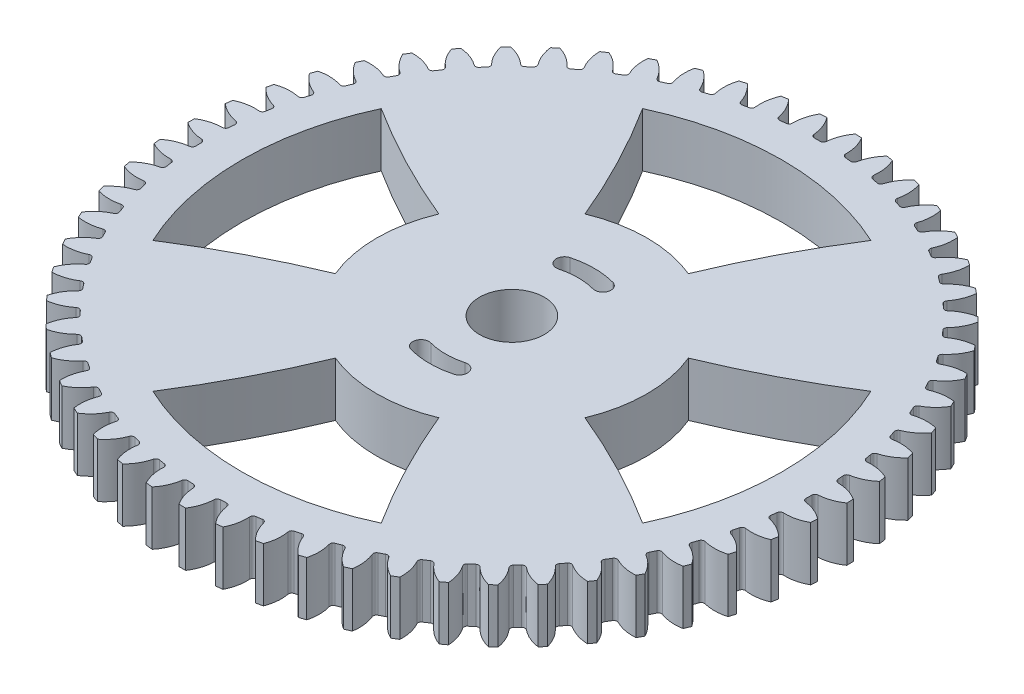
from build123d import *

# Parameters (mm, degrees)
SKETCH1_R                = 61
BOSS_EXTRUDE1_DEPTH      = 10
CUT_EXTRUDE1_DEPTH       = 11
FILLET1_R                = 0.6
CIRPATTERN1_COUNT        = 59
FILLET1_OF_CIRPATTERN1_R = 0.6
CUT_EXTRUDE2_REACH       = 12
SKETCH4_R                = 6
CUT_EXTRUDE3_DEPTH       = 11.0000001
CUT_EXTRUDE5_DEPTH       = 11.0000001


with BuildPart() as part:
    # Sketch1 → Boss-Extrude1 (new body)
    with BuildSketch(Plane(origin=(0, 0, 0), x_dir=(1, 0, 0), z_dir=(0, 1, 0))):
        Circle(SKETCH1_R)
    extrude(amount=BOSS_EXTRUDE1_DEPTH)

    # Sketch3 → Cut-Extrude1 (cut, through all)
    with BuildSketch(Plane(origin=(0, 10, 0), x_dir=(1, 0, 0), z_dir=(0, 1, 0))):
        with BuildLine():
            ThreePointArc((-1.106387044, 56.489166286), (0, 56.5), (1.106387044, 56.489166286))
            ThreePointArc((1.106387044, 56.489166286), (1.519793903, 58.835056548), (2.628503802, 60.943342276))
            ThreePointArc((2.628503802, 60.943342276), (0, 61), (-2.628503802, 60.943342276))
            ThreePointArc((-2.628503802, 60.943342276), (-1.519793903, 58.835056548), (-1.106387044, 56.489166286))
        make_face()
    cut_extrude1 = extrude(amount=-CUT_EXTRUDE1_DEPTH, mode=Mode.SUBTRACT)

    # Fillet1
    fillet1_edges = [part.edges().sort_by_distance(p)[0] for p in [
        (1.106387044, 5, -56.489166286),
        (-1.106387044, 5, -56.489166286),
    ]]
    fillet(fillet1_edges, radius=FILLET1_R)

    # CirPattern1: Cut-Extrude1 ×59 about axis
    cirpattern1_axis = Axis((0, 0, 0), (0, 1, 0))
    for i in range(1, CIRPATTERN1_COUNT):
        add(cut_extrude1.rotate(cirpattern1_axis, i * 360 / CIRPATTERN1_COUNT), mode=Mode.SUBTRACT)

    # Fillet1 of CirPattern1
    fillet1_of_cirpattern1_edges = [part.edges().sort_by_distance(p)[0] for p in [
        (-4.904311245, 5, -56.286745609),
        (-7.104549526, 5, -56.051542138),
        (-10.859441729, 5, -55.446573612),
        (-13.022214624, 5, -54.97883162),
        (-16.691530398, 5, -53.978169782),
        (-18.792332826, 5, -53.283188971),
        (-22.334497359, 5, -51.898171719),
        (-24.349526388, 5, -50.983826501),
        (-27.72440554, 5, -49.230146633),
        (-29.630830087, 5, -48.106796904),
        (-32.800185128, 5, -46.004324314),
        (-34.576404641, 5, -44.684698076),
        (-37.504325512, 5, -42.257254618),
        (-39.130214714, 5, -40.756303763),
        (-41.783526902, 5, -38.031393343),
        (-43.240663819, 5, -36.366124244),
        (-45.589304237, 5, -33.374621184),
        (-46.861178925, 5, -31.563902005),
        (-48.878536538, 5, -28.339701232),
        (-49.950738148, 5, -26.404048145),
        (-51.613955489, 5, -22.98368114),
        (-52.47433555, 5, -20.945025868),
        (-53.764567701, 5, -17.367246758),
        (-54.403377761, 5, -15.24868808),
        (-55.306005877, 5, -11.55403453),
        (-55.716007965, 5, -9.379576562),
        (-56.220804908, 5, -5.609910474),
        (-56.397353535, 5, -3.404190694),
        (-56.498599754, 5, 0.397776109),
        (-56.439694554, 5, 2.609766015),
        (-56.136242889, 5, 6.40095573),
        (-55.842551282, 5, 8.594153032),
        (-55.137839962, 5, 12.331609965),
        (-54.61268959, 5, 14.481164861),
        (-53.514703276, 5, 18.122542131),
        (-52.764044303, 5, 20.204099306),
        (-51.285223618, 5, 23.708138654),
        (-50.317561311, 5, 25.698113233),
        (-48.474661884, 5, 29.025112493),
        (-47.300960243, 5, 30.900957268),
        (-45.114862862, 5, 34.013220209),
        (-43.748420395, 5, 35.75368111),
        (-41.243894416, 5, 38.615944549),
        (-39.700193463, 5, 40.201301459),
        (-36.905616167, 5, 42.781134807),
        (-35.202147476, 5, 44.193424999),
        (-32.149182539, 5, 46.461597713),
        (-30.305247091, 5, 47.684819374),
        (-27.028485827, 5, 49.615632153),
        (-25.064976148, 5, 50.635925692),
        (-21.601545571, 5, 52.207501654),
        (-19.54070901, 5, 53.013306739),
        (-15.929851172, 5, 54.207839301),
        (-13.79503783, 5, 54.790025837),
        (-10.077665193, 5, 55.593980468),
        (-7.89306336, 5, 55.94595205),
        (-4.111295242, 5, 56.350219622),
        (-1.901657328, 5, 56.467988271),
        (1.901657328, 5, 56.467988271),
        (4.111295242, 5, 56.350219622),
        (7.89306336, 5, 55.94595205),
        (10.077665193, 5, 55.593980468),
        (13.79503783, 5, 54.790025837),
        (15.929851172, 5, 54.207839301),
        (19.54070901, 5, 53.013306739),
        (21.601545571, 5, 52.207501654),
        (25.064976148, 5, 50.635925692),
        (27.028485827, 5, 49.615632153),
        (30.305247091, 5, 47.684819374),
        (32.149182539, 5, 46.461597713),
        (35.202147476, 5, 44.193424999),
        (36.905616167, 5, 42.781134807),
        (39.700193463, 5, 40.201301459),
        (41.243894416, 5, 38.615944549),
        (43.748420395, 5, 35.75368111),
        (45.114862862, 5, 34.013220209),
        (47.300960243, 5, 30.900957268),
        (48.474661884, 5, 29.025112493),
        (50.317561311, 5, 25.698113233),
        (51.285223618, 5, 23.708138654),
        (52.764044303, 5, 20.204099306),
        (53.514703276, 5, 18.122542131),
        (54.61268959, 5, 14.481164861),
        (55.137839962, 5, 12.331609965),
        (55.842551282, 5, 8.594153032),
        (56.136242889, 5, 6.40095573),
        (56.439694554, 5, 2.609766015),
        (56.498599754, 5, 0.397776109),
        (56.397353535, 5, -3.404190694),
        (56.220804908, 5, -5.609910474),
        (55.716007965, 5, -9.379576562),
        (55.306005877, 5, -11.55403453),
        (54.403377761, 5, -15.24868808),
        (53.764567701, 5, -17.367246758),
        (52.47433555, 5, -20.945025868),
        (51.613955489, 5, -22.98368114),
        (49.950738148, 5, -26.404048145),
        (48.878536538, 5, -28.339701232),
        (46.861178925, 5, -31.563902005),
        (45.589304237, 5, -33.374621184),
        (43.240663819, 5, -36.366124244),
        (41.783526902, 5, -38.031393343),
        (39.130214714, 5, -40.756303763),
        (37.504325512, 5, -42.257254618),
        (34.576404641, 5, -44.684698076),
        (32.800185128, 5, -46.004324314),
        (29.630830087, 5, -48.106796904),
        (27.72440554, 5, -49.230146633),
        (24.349526388, 5, -50.983826501),
        (22.334497359, 5, -51.898171719),
        (18.792332826, 5, -53.283188971),
        (16.691530398, 5, -53.978169782),
        (13.022214624, 5, -54.97883162),
        (10.859441729, 5, -55.446573612),
        (7.104549526, 5, -56.051542138),
        (4.904311245, 5, -56.286745609),
    ]]
    fillet(fillet1_of_cirpattern1_edges, radius=FILLET1_OF_CIRPATTERN1_R)

    # Sketch4 → Cut-Extrude2 (cut, up to next)
    with BuildSketch(Plane(origin=(0, 10, 0), x_dir=(1, 0, 0), z_dir=(0, 1, 0)), mode=Mode.PRIVATE) as cut_extrude2_sk1:
        Circle(SKETCH4_R)
    cut_extrude2_tool1 = extrude(cut_extrude2_sk1.sketch, amount=-CUT_EXTRUDE2_REACH, mode=Mode.PRIVATE) & part.part
    add(cut_extrude2_tool1.solids().sort_by_distance((0, 10, 0))[0], mode=Mode.SUBTRACT)

    # Sketch5 → Cut-Extrude3 (cut, through all)
    with BuildSketch(Plane(origin=(0, 10, 0), x_dir=(1, 0, 0), z_dir=(0, 1, 0))):
        with BuildLine():
            ThreePointArc((-3.946990438, 14.730368851), (-5.00765061, 12.893251544), (-3.170533303, 11.832591372))
            ThreePointArc((-3.170533303, 11.832591372), (0, 12.25), (3.170533303, 11.832591372))
            ThreePointArc((3.170533303, 11.832591372), (5.00765061, 12.893251544), (3.946990438, 14.730368851))
            ThreePointArc((3.946990438, 14.730368851), (0, 15.25), (-3.946990438, 14.730368851))
        make_face()
        with BuildLine():
            ThreePointArc((3.946990438, -14.730368851), (0, -15.25), (-3.946990438, -14.730368851))
            ThreePointArc((-3.946990438, -14.730368851), (-5.00765061, -12.893251544), (-3.170533303, -11.832591372))
            ThreePointArc((-3.170533303, -11.832591372), (0, -12.25), (3.170533303, -11.832591372))
            ThreePointArc((3.170533303, -11.832591372), (5.00765061, -12.893251544), (3.946990438, -14.730368851))
        make_face()
    extrude(amount=-CUT_EXTRUDE3_DEPTH, mode=Mode.SUBTRACT)

    # Sketch9 → Cut-Extrude5 (cut, through all)
    with BuildSketch(Plane(origin=(0, 10, 0), x_dir=(1, 0, 0), z_dir=(0, 1, 0))):
        with BuildLine():
            ThreePointArc((21.130913087, 45.315389352), (0, 50), (-21.130913087, 45.315389352))
            ThreePointArc((-21.130913087, 45.315389352), (-14.864422489, 34.458392591), (-9.567085809, 23.096988313))
            ThreePointArc((-9.567085809, 23.096988313), (0, 25), (9.567085809, 23.096988313))
            ThreePointArc((9.567085809, 23.096988313), (14.864422489, 34.458392591), (21.130913087, 45.315389352))
        make_face()
        with BuildLine():
            ThreePointArc((23.096988313, -9.567085809), (25, 0), (23.096988313, 9.567085809))
            ThreePointArc((23.096988313, 9.567085809), (34.458392591, 14.864422489), (45.315389352, 21.130913087))
            ThreePointArc((45.315389352, 21.130913087), (50, 0), (45.315389352, -21.130913087))
            ThreePointArc((45.315389352, -21.130913087), (34.458392591, -14.864422489), (23.096988313, -9.567085809))
        make_face()
        with BuildLine():
            ThreePointArc((-9.567085809, -23.096988313), (0, -25), (9.567085809, -23.096988313))
            ThreePointArc((9.567085809, -23.096988313), (14.864422489, -34.458392591), (21.130913087, -45.315389352))
            ThreePointArc((21.130913087, -45.315389352), (0, -50), (-21.130913087, -45.315389352))
            ThreePointArc((-21.130913087, -45.315389352), (-14.864422489, -34.458392591), (-9.567085809, -23.096988313))
        make_face()
        with BuildLine():
            ThreePointArc((-23.096988313, 9.567085809), (-25, 0), (-23.096988313, -9.567085809))
            ThreePointArc((-23.096988313, -9.567085809), (-34.458392591, -14.864422489), (-45.315389352, -21.130913087))
            ThreePointArc((-45.315389352, -21.130913087), (-50, 0), (-45.315389352, 21.130913087))
            ThreePointArc((-45.315389352, 21.130913087), (-34.458392591, 14.864422489), (-23.096988313, 9.567085809))
        make_face()
    extrude(amount=-CUT_EXTRUDE5_DEPTH, mode=Mode.SUBTRACT)


solid = part.part
